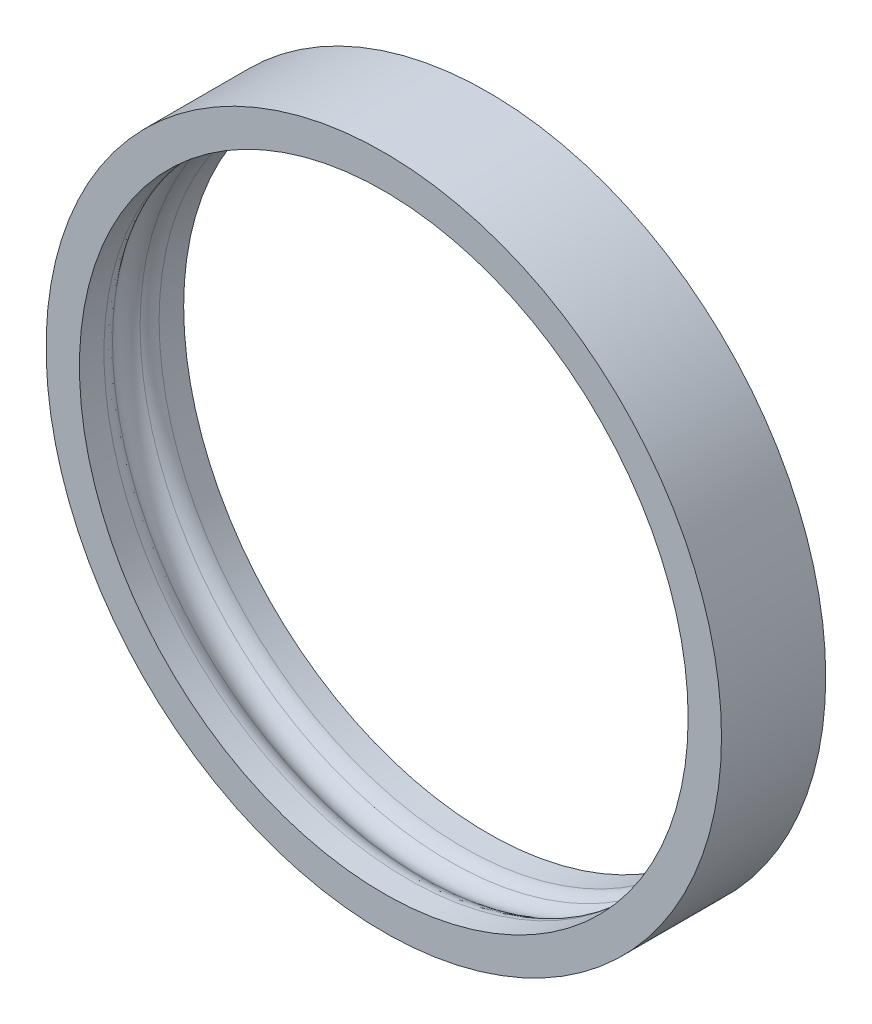
from build123d import *

# Parameters (mm, degrees)
SKETCH_1_R      = 16.2
SKETCH_1_R_2    = 14.6
EXTRUDE_1_DEPTH = 2.5
SKETCH_3_R      = 1
FILLET_1_R      = 1


with BuildPart() as part:
    # 草图1 → 凸台-拉伸1 (new body, symmetric)
    with BuildSketch(Plane.XY):
        Circle(SKETCH_1_R)
        Circle(SKETCH_1_R_2, mode=Mode.SUBTRACT)
    extrude(amount=EXTRUDE_1_DEPTH, both=True)

    # 草图3 → 切除-旋转1 (revolve, cut)
    with BuildSketch(Plane(origin=(0, 0, 0), x_dir=(1, 0, 0), z_dir=(0, 1, 0))):
        with Locations((-14.1, 0)):
            Circle(SKETCH_3_R)
    revolve(axis=Axis((0, 0, 2.5), (0, 0, -1)), mode=Mode.SUBTRACT)

    # 圆角1
    fillet_1_edges = [part.edges().sort_by_distance(p)[0] for p in [
        (0, 14.6, 0.866025404),
        (0, -14.6, -0.866025404),
    ]]
    fillet(fillet_1_edges, radius=FILLET_1_R)


solid = part.part
